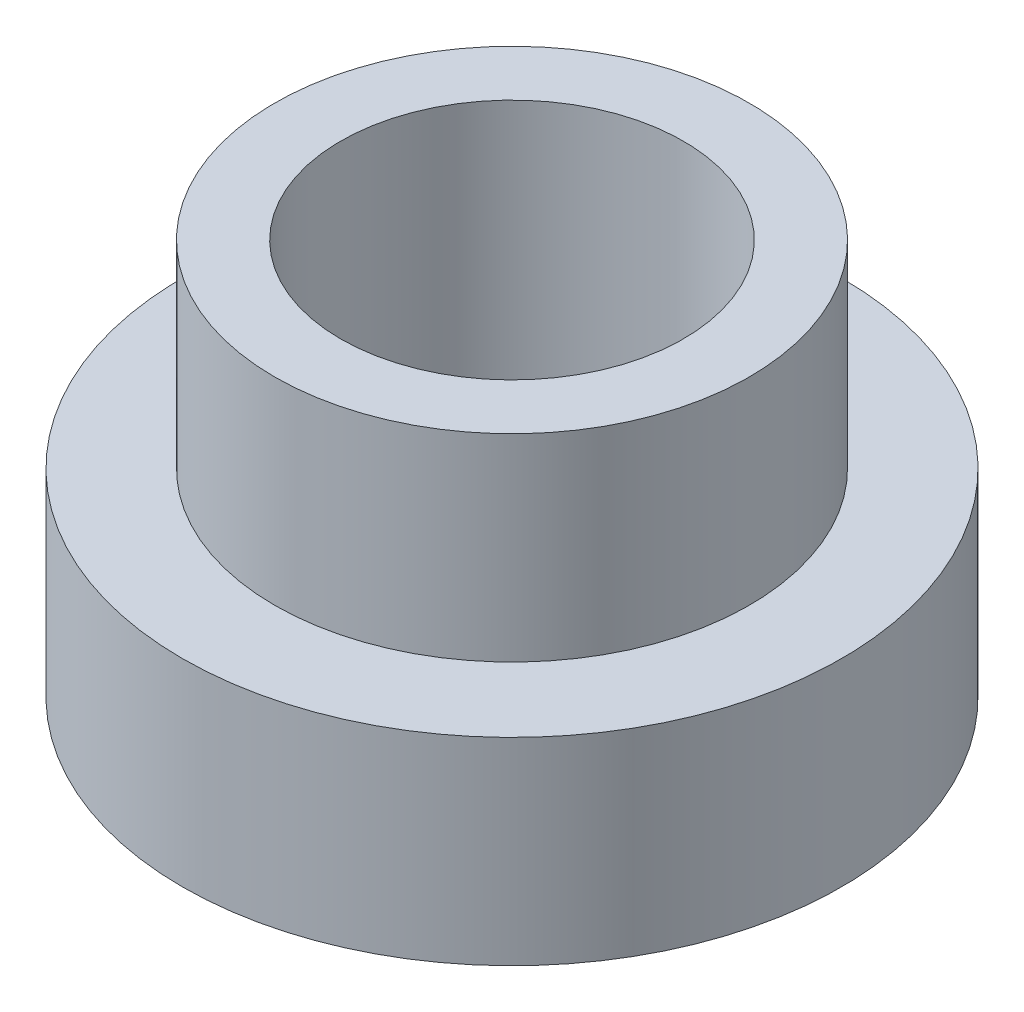
from build123d import *

# Parameters (mm, degrees)
SKETCH1_R           = 5
BOSS_EXTRUDE1_DEPTH = 3
SKETCH2_R           = 3.6
BOSS_EXTRUDE2_DEPTH = 3
SKETCH3_R           = 2.6
CUT_EXTRUDE1_DEPTH  = 7


with BuildPart() as part:
    # Sketch1 → Boss-Extrude1 (new body)
    with BuildSketch(Plane(origin=(0, 0, 0), x_dir=(1, 0, 0), z_dir=(0, 1, 0))):
        Circle(SKETCH1_R)
    extrude(amount=BOSS_EXTRUDE1_DEPTH)

    # Sketch2 → Boss-Extrude2 (add)
    with BuildSketch(Plane(origin=(0, 3, 0), x_dir=(1, 0, 0), z_dir=(0, 1, 0))):
        Circle(SKETCH2_R)
    extrude(amount=BOSS_EXTRUDE2_DEPTH)

    # Sketch3 → Cut-Extrude1 (cut, through all)
    with BuildSketch(Plane(origin=(0, 0, 0), x_dir=(1, 0, 0), z_dir=(0, 1, 0))):
        Circle(SKETCH3_R)
    extrude(amount=CUT_EXTRUDE1_DEPTH, mode=Mode.SUBTRACT)


solid = part.part
